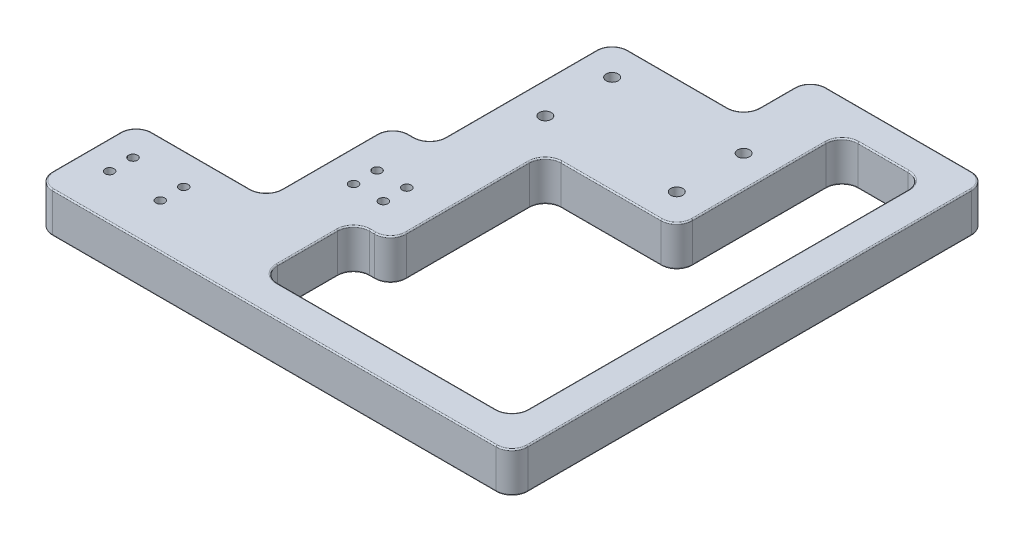
from build123d import *

# Parameters (mm, degrees)
SKETCH1_W               = 150
SKETCH1_H               = 150
BOSS_EXTRUDE1_DEPTH     = 12.7
M3_CLEARANCE_HOLE1_D    = 2.8
M4_CLEARANCE_HOLE1_D    = 3.8
SKETCH14_W              = 52.65
SKETCH14_H              = 78.6
SKETCH14_W_2            = 41
SKETCH14_H_2            = 40
SKETCH14_W_3            = 67.35
SKETCH14_H_3            = 77.849261314
SKETCH14_W_4            = 25.85
SKETCH14_H_4            = 52.150738686
SKETCH14_W_5            = 41.5
SKETCH14_H_5            = 21.050738686
SKETCH14_W_6            = 11.65
SKETCH14_H_6            = 29
CUT_EXTRUDE1_DEPTH      = 1
CUT_EXTRUDE1_DEPTH_BACK = 13.7
FILLET1_R               = 5
FILLET2_R               = 0.4


with BuildPart() as part:
    # Sketch1 → Boss-Extrude1 (new body)
    with BuildSketch(Plane(origin=(0, 0, 0), x_dir=(1, 0, 0), z_dir=(0, 1, 0))):
        with Locations((75, 75)):
            Rectangle(SKETCH1_W, SKETCH1_H)
    extrude(amount=BOSS_EXTRUDE1_DEPTH)

    # M3 Clearance Hole1 (through all)
    with Locations(Plane(origin=(0, 12.7, 0), x_dir=(1, 0, 0), z_dir=(0, 1, 0))):
        with Locations((9, 21.4), (25, 21.4), (25, 14), (9, 14), (51, 56.4), (60.4, 56.4), (60.4, 49), (51, 49)):
            Hole(M3_CLEARANCE_HOLE1_D / 2)

    # M4 Clearance Hole1 (through all)
    with Locations(Plane(origin=(0, 12.7, 0), x_dir=(1, 0, 0), z_dir=(0, 1, 0))):
        with Locations((62.65, 97.849261314), (62.65, 118.949261314), (104.15, 118.949261314), (104.15, 97.849261314)):
            Hole(M4_CLEARANCE_HOLE1_D / 2)

    # Sketch14 → Cut-Extrude1 (cut, two sides)
    with BuildSketch(Plane(origin=(0, 12.7, 0), x_dir=(1, 0, 0), z_dir=(0, 1, 0))) as cut_extrude1_sk:
        with Locations((26.325, 110.7)):
            Rectangle(SKETCH14_W, SKETCH14_H)
        with Locations((20.5, 51.4)):
            Rectangle(SKETCH14_W_2, SKETCH14_H_2)
        with Locations((106.325, 48.924630657)):
            Rectangle(SKETCH14_W_3, SKETCH14_H_3)
        with Locations((127.075, 113.924630657)):
            Rectangle(SKETCH14_W_4, SKETCH14_H_4)
        with Locations((73.4, 139.474630657)):
            Rectangle(SKETCH14_W_5, SKETCH14_H_5)
        with Locations((66.825, 24.5)):
            Rectangle(SKETCH14_W_6, SKETCH14_H_6)
    extrude(amount=CUT_EXTRUDE1_DEPTH, mode=Mode.SUBTRACT)
    extrude(cut_extrude1_sk.sketch, amount=-CUT_EXTRUDE1_DEPTH_BACK, mode=Mode.SUBTRACT)

    # Fillet1
    fillet1_edges = [part.edges().sort_by_distance(p)[0] for p in [
        (140, 6.35, -140),
        (140, 6.35, -10),
        (61, 6.35, -10),
        (61, 6.35, -39),
        (72.65, 6.35, -39),
        (72.65, 6.35, -87.849261314),
        (114.15, 6.35, -87.849261314),
        (114.15, 6.35, -140),
        (52.65, 6.35, -128.949261314),
        (52.65, 6.35, -71.4),
        (41, 6.35, -71.4),
        (41, 6.35, -31.4),
        (0, 6.35, -31.4),
        (94.15, 6.35, -150),
        (94.15, 6.35, -128.949261314),
        (150, 6.35, -150),
        (150, 6.35, 0),
        (0, 6.35, 0),
    ]]
    fillet(fillet1_edges, radius=FILLET1_R)

    # Fillet2
    fillet2_edges = [part.edges().sort_by_distance(p)[0] for p in [
        (100.5, 0, -10),
        (100.5, 12.7, -10),
        (61, 12.7, -24.5),
        (61, 0, -24.5),
        (66.825, 0, -39),
        (66.825, 12.7, -39),
        (41, 12.7, -51.4),
        (20.5, 12.7, -31.4),
        (0, 12.7, -15.7),
        (75, 12.7, 0),
        (150, 12.7, -75),
        (122.075, 12.7, -150),
        (94.15, 12.7, -139.474630657),
        (73.4, 12.7, -128.949261314),
        (52.65, 12.7, -100.174630657),
        (46.825, 12.7, -71.4),
        (140, 12.7, -75),
        (72.65, 12.7, -63.424630657),
        (93.4, 12.7, -87.849261314),
        (114.15, 12.7, -113.924630657),
        (127.075, 12.7, -140),
        (1.464466094, 12.7, -29.935533906),
        (54.114466094, 12.7, -127.48479522),
        (95.614466094, 12.7, -148.535533906),
        (42.464466094, 12.7, -69.935533906),
        (1.464466094, 12.7, -1.464466094),
        (148.535533906, 12.7, -1.464466094),
        (148.535533906, 12.7, -148.535533906),
        (112.685533906, 12.7, -89.313727408),
        (71.185533906, 12.7, -40.464466094),
        (72.65, 0, -63.424630657),
        (20.5, 0, -31.4),
        (41, 0, -51.4),
        (46.825, 0, -71.4),
        (52.65, 0, -100.174630657),
        (73.4, 0, -128.949261314),
        (94.15, 0, -139.474630657),
        (122.075, 0, -150),
        (150, 0, -75),
        (75, 0, 0),
        (0, 0, -15.7),
        (140, 0, -75),
        (127.075, 0, -140),
        (114.15, 0, -113.924630657),
        (93.4, 0, -87.849261314),
        (1.464466094, 0, -29.935533906),
        (54.114466094, 0, -127.48479522),
        (95.614466094, 0, -148.535533906),
        (42.464466094, 0, -69.935533906),
        (1.464466094, 0, -1.464466094),
        (148.535533906, 0, -1.464466094),
        (148.535533906, 0, -148.535533906),
        (112.685533906, 0, -89.313727408),
        (71.185533906, 0, -40.464466094),
        (62.464466094, 12.7, -11.464466094),
        (62.464466094, 0, -11.464466094),
        (62.464466094, 12.7, -37.535533906),
        (62.464466094, 0, -37.535533906),
        (138.535533906, 12.7, -138.535533906),
        (138.535533906, 0, -138.535533906),
        (115.614466094, 12.7, -138.535533906),
        (115.614466094, 0, -138.535533906),
        (39.535533906, 12.7, -32.864466094),
        (39.535533906, 0, -32.864466094),
        (51.185533906, 12.7, -72.864466094),
        (51.185533906, 0, -72.864466094),
        (138.535533906, 12.7, -11.464466094),
        (138.535533906, 0, -11.464466094),
        (74.114466094, 12.7, -86.38479522),
        (74.114466094, 0, -86.38479522),
        (92.685533906, 12.7, -130.413727408),
        (92.685533906, 0, -130.413727408),
    ]]
    fillet(fillet2_edges, radius=FILLET2_R)


solid = part.part
